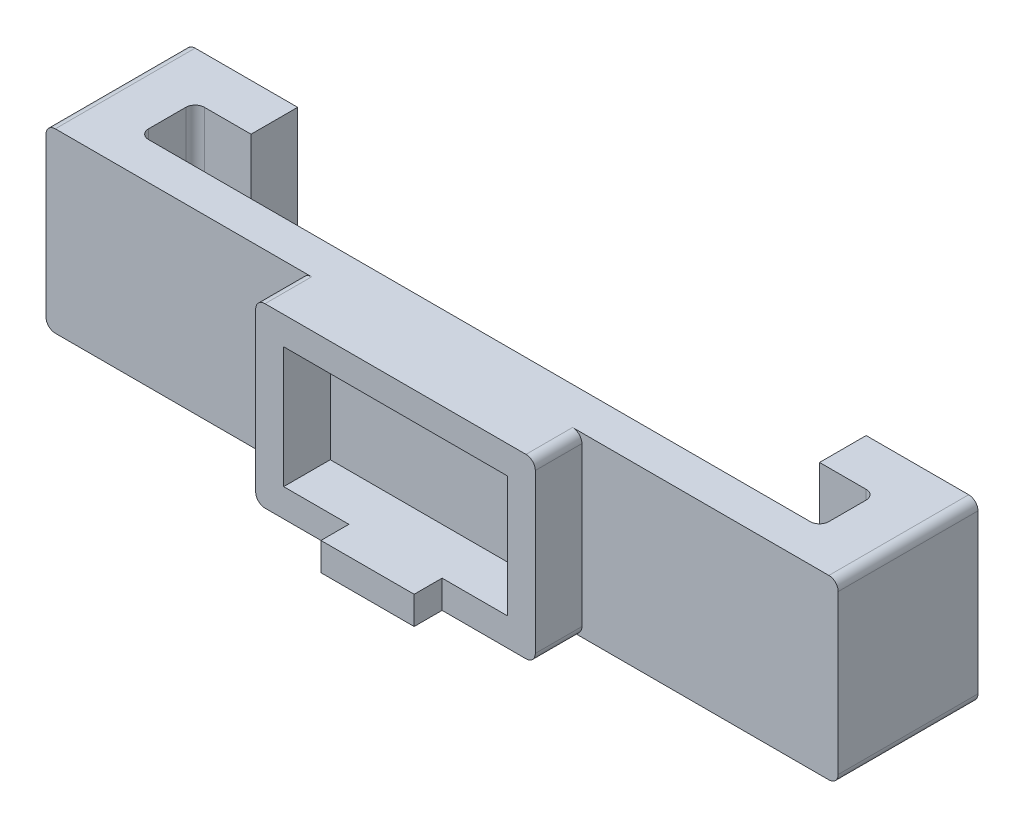
from build123d import *

# Parameters (mm, degrees)
SKETCH1_W           = 30
SKETCH1_H           = 19
SKETCH1_W_2         = 24
SKETCH1_H_2         = 13
BOSS_EXTRUDE1_DEPTH = 5
BOSS_EXTRUDE4_DEPTH = 4
SKETCH4_W           = 6
SKETCH4_H           = 19
BOSS_EXTRUDE5_DEPTH = 6
LPATTERN1_COUNT     = 2
LPATTERN1_PITCH     = 79
SKETCH6_W           = 12
SKETCH6_H           = 19
BOSS_EXTRUDE6_DEPTH = 5
LPATTERN2_COUNT     = 2
LPATTERN2_PITCH     = 73
BOSS_EXTRUDE7_DEPTH = 3
FILLET1_R           = 1
FILLET2_R           = 1
FILLET3_R           = 1


with BuildPart() as part:
    # Sketch1 → Boss-Extrude1 (new body)
    with BuildSketch(Plane.XY):
        with Locations((12, 6.5)):
            Rectangle(SKETCH1_W, SKETCH1_H)
        with Locations((12, 6.5)):
            Rectangle(SKETCH1_W_2, SKETCH1_H_2, mode=Mode.SUBTRACT)
    extrude(amount=BOSS_EXTRUDE1_DEPTH)

    # Sketch3 → Boss-Extrude4 (add)
    with BuildSketch(Plane(origin=(0, 0, 0), x_dir=(-1, 0, 0), z_dir=(0, 0, -1))):
        Polygon((-12, 16), (-54.5, 16), (-54.5, -3), (-7, -3), (30.5, -3), (30.5, 16), align=None)
    extrude(amount=BOSS_EXTRUDE4_DEPTH)

    # Sketch4 → Boss-Extrude5 (add)
    with BuildSketch(Plane(origin=(0, 0, -4), x_dir=(-1, 0, 0), z_dir=(0, 0, -1))):
        with Locations((-51.5, 6.5)):
            Rectangle(SKETCH4_W, SKETCH4_H)
    boss_extrude5 = extrude(amount=BOSS_EXTRUDE5_DEPTH)

    # LPattern1: Boss-Extrude5 ×2
    with Locations(*[(-i * LPATTERN1_PITCH, 0, 0) for i in range(1, LPATTERN1_COUNT)]):
        add(boss_extrude5)

    # Sketch6 → Boss-Extrude6 (add)
    with BuildSketch(Plane(origin=(0, 0, -10), x_dir=(-1, 0, 0), z_dir=(0, 0, -1))):
        with Locations((-48.5, 6.5)):
            Rectangle(SKETCH6_W, SKETCH6_H)
    boss_extrude6 = extrude(amount=BOSS_EXTRUDE6_DEPTH)

    # LPattern2: Boss-Extrude6 ×2
    with Locations(*[(-i * LPATTERN2_PITCH, 0, 0) for i in range(1, LPATTERN2_COUNT)]):
        add(boss_extrude6)

    # Sketch7 → Boss-Extrude7 (add)
    with BuildSketch(Plane.XY.offset(5)):
        Polygon((12, 0), (7, 0), (7, -3), (12, -3), (17, -3), (17, 0), align=None)
    extrude(amount=BOSS_EXTRUDE7_DEPTH)

    # Fillet1
    fillet1_edges = [part.edges().sort_by_distance(p)[0] for p in [
        (-3, 16, 2.5),
        (27, 16, 2.5),
        (27, -3, 2.5),
        (-3, -3, 2.5),
    ]]
    fillet(fillet1_edges, radius=FILLET1_R)

    # Fillet2
    fillet2_edges = [part.edges().sort_by_distance(p)[0] for p in [
        (54.5, 16, -7.5),
        (54.5, -3, -7.5),
        (-30.5, -3, -7.5),
        (-30.5, 16, -7.5),
    ]]
    fillet(fillet2_edges, radius=FILLET2_R)

    # Fillet3
    fillet3_edges = [part.edges().sort_by_distance(p)[0] for p in [
        (48.5, 6.5, -4),
        (48.5, 6.5, -10),
        (-24.5, 6.5, -4),
        (-24.5, 6.5, -10),
    ]]
    fillet(fillet3_edges, radius=FILLET3_R)


solid = part.part
